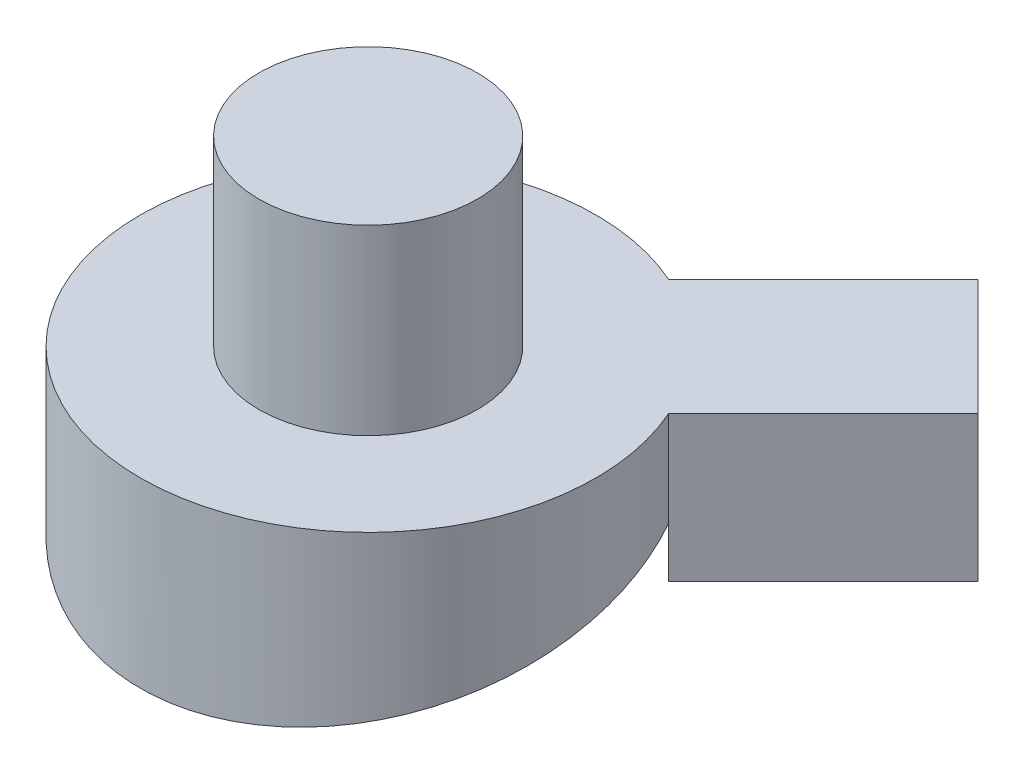
from build123d import *

# Parameters (mm, degrees)
SKETCH2_R               = 62.5
BOSS_EXTRUDE1_DEPTH     = 50
CUT_EXTRUDE1_DEPTH      = 63.5
CUT_EXTRUDE1_DEPTH_BACK = 63.5
SKETCH4_R               = 30
BOSS_EXTRUDE2_DEPTH     = 50
SKETCH5_R               = 50
CUT_EXTRUDE2_DEPTH      = 33.808019269
CUT_EXTRUDE2_DEPTH_BACK = 10
BOSS_EXTRUDE3_DEPTH     = 40


with BuildPart() as part:
    # Sketch2 → Boss-Extrude1 (new body)
    with BuildSketch(Plane(origin=(0, 0, 0), x_dir=(1, 0, 0), z_dir=(0, 1, 0))):
        Circle(SKETCH2_R)
    extrude(amount=BOSS_EXTRUDE1_DEPTH)

    # Sketch3 → Cut-Extrude1 (cut, two sides)
    with BuildSketch(Plane(origin=(0, 0, 0), x_dir=(0, 0, -1), z_dir=(1, 0, 0))) as cut_extrude1_sk:
        Polygon((-62.5, 0), (62.5, 34), (62.5, 0), align=None)
    extrude(amount=CUT_EXTRUDE1_DEPTH, mode=Mode.SUBTRACT)
    extrude(cut_extrude1_sk.sketch, amount=-CUT_EXTRUDE1_DEPTH_BACK, mode=Mode.SUBTRACT)

    # Sketch4 → Boss-Extrude2 (add)
    with BuildSketch(Plane(origin=(0, 50, 0), x_dir=(1, 0, 0), z_dir=(0, 1, 0))):
        Circle(SKETCH4_R)
    extrude(amount=BOSS_EXTRUDE2_DEPTH)

    # Sketch5 → Cut-Extrude2 (cut, two sides)
    with BuildSketch(Plane(origin=(0, 15.828913652, 4.305464513), x_dir=(1, 0, 0), z_dir=(0, -0.964941743, -0.262464154))) as cut_extrude2_sk:
        with Locations((0, -4.461890621)):
            Circle(SKETCH5_R)
    extrude(amount=CUT_EXTRUDE2_DEPTH, mode=Mode.SUBTRACT)
    extrude(cut_extrude2_sk.sketch, amount=-CUT_EXTRUDE2_DEPTH_BACK, mode=Mode.SUBTRACT)

    # Sketch7 → Revolve1 (revolve)
    with BuildSketch(Plane(origin=(0, 0, 0), x_dir=(0, 0, -1), z_dir=(1, 0, 0))):
        Polygon((-50.871728702, 13.526209724), (-1.273723101, 14.062717334), (0.656160385, 14.587645642), (-2.624641542, 26.649417432), align=None)
    revolve(axis=Axis((0, 14.587645642, -0.656160385), (0, 0.964941743, 0.262464154)))

    # Sketch8 → Boss-Extrude3 (add)
    with BuildSketch(Plane(origin=(0, 50, 0), x_dir=(1, 0, 0), z_dir=(0, 1, 0))):
        with BuildLine():
            Line((25.321153679, 57.140958833), (67.747560551, 99.567365704))
            Line((67.747560551, 99.567365704), (99.567365704, 67.747560551))
            Line((99.567365704, 67.747560551), (57.140958833, 25.321153679))
            ThreePointArc((57.140958833, 25.321153679), (44.194173824, 44.194173824), (25.321153679, 57.140958833))
        make_face()
    extrude(amount=-BOSS_EXTRUDE3_DEPTH)


solid = part.part
